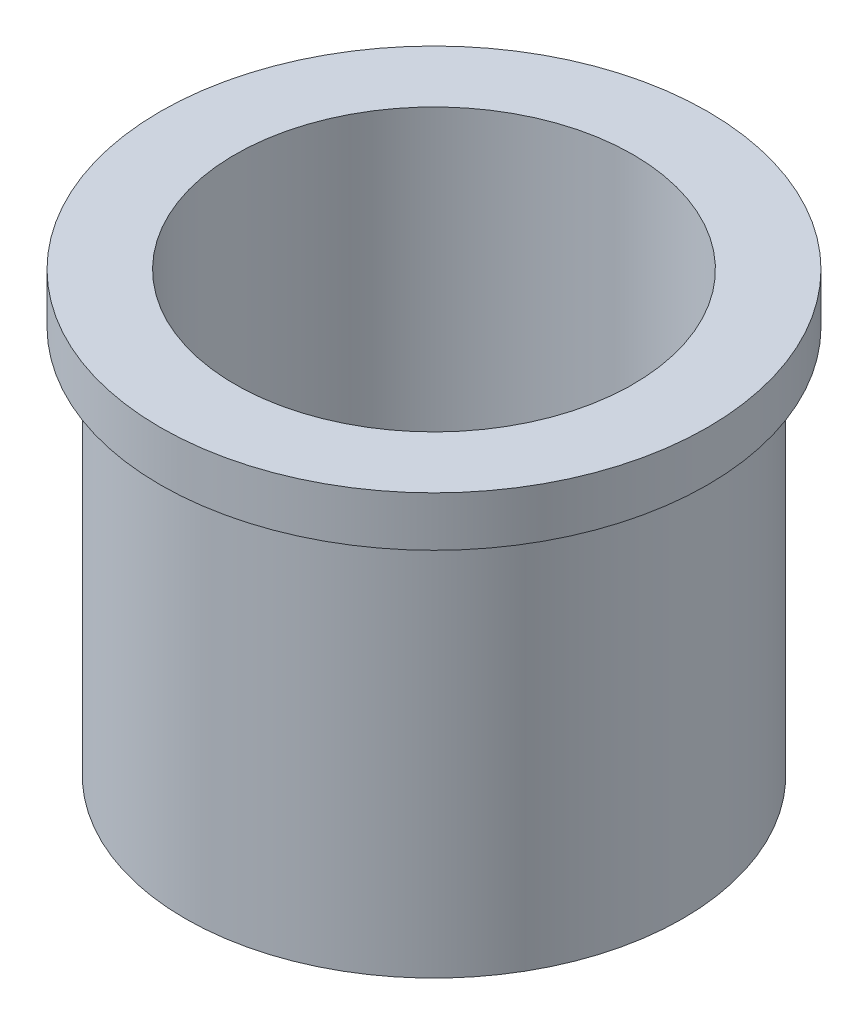
from build123d import *

# Parameters (mm, degrees)
SKETCH1_R           = 12.7
BOSS_EXTRUDE1_DEPTH = 19.812
SKETCH2_R           = 13.97
BOSS_EXTRUDE2_DEPTH = 2.54
SKETCH3_R           = 10.16
CUT_EXTRUDE1_DEPTH  = 23.352


with BuildPart() as part:
    # Sketch1 → Boss-Extrude1 (new body)
    with BuildSketch(Plane(origin=(0, 0, 0), x_dir=(1, 0, 0), z_dir=(0, 1, 0))):
        Circle(SKETCH1_R)
    extrude(amount=BOSS_EXTRUDE1_DEPTH)

    # Sketch2 → Boss-Extrude2 (add)
    with BuildSketch(Plane(origin=(0, 19.812, 0), x_dir=(1, 0, 0), z_dir=(0, 1, 0))):
        Circle(SKETCH2_R)
    extrude(amount=BOSS_EXTRUDE2_DEPTH)

    # Sketch3 → Cut-Extrude1 (cut, through all)
    with BuildSketch(Plane.XZ):
        Circle(SKETCH3_R)
    extrude(amount=-CUT_EXTRUDE1_DEPTH, mode=Mode.SUBTRACT)


solid = part.part
